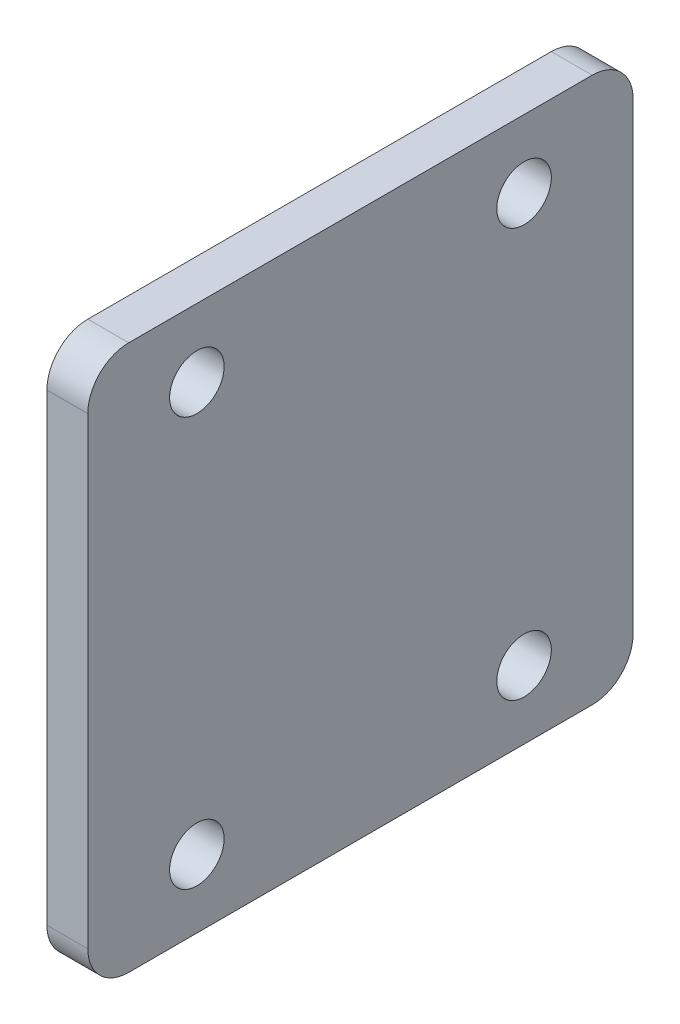
from build123d import *

# Parameters (mm, degrees)
SKETCH1_W           = 40
SKETCH1_H           = 40
BOSS_EXTRUDE1_DEPTH = 3
FILLET1_R           = 3
CUT_EXTRUDE1_REACH  = 5
SKETCH2_R           = 2


with BuildPart() as part:
    # Sketch1 → Boss-Extrude1 (new body)
    with BuildSketch(Plane.ZY.offset(26.051745534)):
        with Locations((-36.163138966, 1200.261717599)):
            Rectangle(SKETCH1_W, SKETCH1_H)
    extrude(amount=BOSS_EXTRUDE1_DEPTH)

    # Fillet1
    fillet1_edges = [part.edges().sort_by_distance(p)[0] for p in [
        (-27.551745534, 1220.261717599, -56.163138966),
        (-27.551745534, 1220.261717599, -16.163138966),
        (-27.551745534, 1180.261717599, -16.163138966),
        (-27.551745534, 1180.261717599, -56.163138966),
    ]]
    fillet(fillet1_edges, radius=FILLET1_R)

    # Sketch2 → Cut-Extrude1 (cut, up to next)
    with BuildSketch(Plane.ZY.offset(29.051745534), mode=Mode.PRIVATE) as cut_extrude1_sk1:
        with Locations((-48.163138966, 1215.261717599)):
            Circle(SKETCH2_R)
    cut_extrude1_tool1 = extrude(cut_extrude1_sk1.sketch, amount=-CUT_EXTRUDE1_REACH, mode=Mode.PRIVATE) & part.part
    add(cut_extrude1_tool1.solids().sort_by_distance((-29.051746, 1215.261718, -48.163139))[0], mode=Mode.SUBTRACT)
    # Sketch2 → Cut-Extrude1 (cut, up to next)
    with BuildSketch(Plane.ZY.offset(29.051745534), mode=Mode.PRIVATE) as cut_extrude1_sk2:
        with Locations((-24.163138966, 1215.261717599)):
            Circle(SKETCH2_R)
    cut_extrude1_tool2 = extrude(cut_extrude1_sk2.sketch, amount=-CUT_EXTRUDE1_REACH, mode=Mode.PRIVATE) & part.part
    add(cut_extrude1_tool2.solids().sort_by_distance((-29.051746, 1215.261718, -24.163139))[0], mode=Mode.SUBTRACT)
    # Sketch2 → Cut-Extrude1 (cut, up to next)
    with BuildSketch(Plane.ZY.offset(29.051745534), mode=Mode.PRIVATE) as cut_extrude1_sk3:
        with Locations((-24.163138966, 1185.261717599)):
            Circle(SKETCH2_R)
    cut_extrude1_tool3 = extrude(cut_extrude1_sk3.sketch, amount=-CUT_EXTRUDE1_REACH, mode=Mode.PRIVATE) & part.part
    add(cut_extrude1_tool3.solids().sort_by_distance((-29.051746, 1185.261718, -24.163139))[0], mode=Mode.SUBTRACT)
    # Sketch2 → Cut-Extrude1 (cut, up to next)
    with BuildSketch(Plane.ZY.offset(29.051745534), mode=Mode.PRIVATE) as cut_extrude1_sk4:
        with Locations((-48.163138966, 1185.261717599)):
            Circle(SKETCH2_R)
    cut_extrude1_tool4 = extrude(cut_extrude1_sk4.sketch, amount=-CUT_EXTRUDE1_REACH, mode=Mode.PRIVATE) & part.part
    add(cut_extrude1_tool4.solids().sort_by_distance((-29.051746, 1185.261718, -48.163139))[0], mode=Mode.SUBTRACT)


solid = part.part
